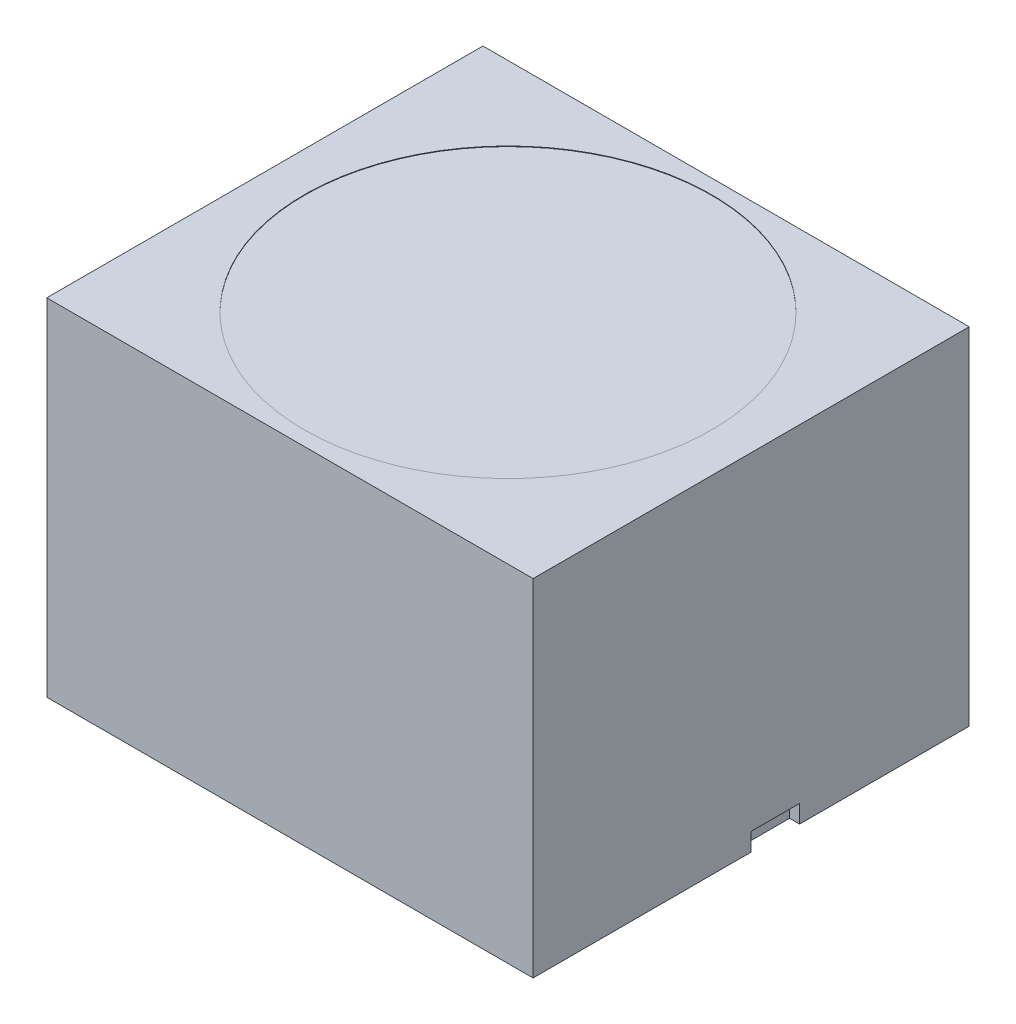
from build123d import *

# Parameters (mm, degrees)
CROQUIS1_W              = 97
CROQUIS1_H              = 87
SALIENTE_EXTRUIR1_DEPTH = 69
CROQUIS2_R              = 40.625765917
CORTAR_EXTRUIR1_DEPTH   = 0.1
CROQUIS3_W              = 9.671731422
CROQUIS3_H              = 3.578358675
CORTAR_EXTRUIR2_DEPTH   = 2


with BuildPart() as part:
    # Croquis1 → Saliente-Extruir1 (new body)
    with BuildSketch(Plane(origin=(0, 0, 0), x_dir=(1, 0, 0), z_dir=(0, 1, 0))):
        Rectangle(CROQUIS1_W, CROQUIS1_H)
    extrude(amount=SALIENTE_EXTRUIR1_DEPTH)

    # Croquis2 → Cortar-Extruir1 (cut)
    with BuildSketch(Plane(origin=(0, 69, 0), x_dir=(1, 0, 0), z_dir=(0, 1, 0))):
        Circle(CROQUIS2_R)
    extrude(amount=-CORTAR_EXTRUIR1_DEPTH, mode=Mode.SUBTRACT)

    # Croquis3 → Cortar-Extruir2 (cut)
    with BuildSketch(Plane(origin=(48.5, 0, 0), x_dir=(0, 0, -1), z_dir=(1, 0, 0))):
        with Locations((4.835865711, 1.789179338)):
            Rectangle(CROQUIS3_W, CROQUIS3_H)
    extrude(amount=-CORTAR_EXTRUIR2_DEPTH, mode=Mode.SUBTRACT)


solid = part.part
